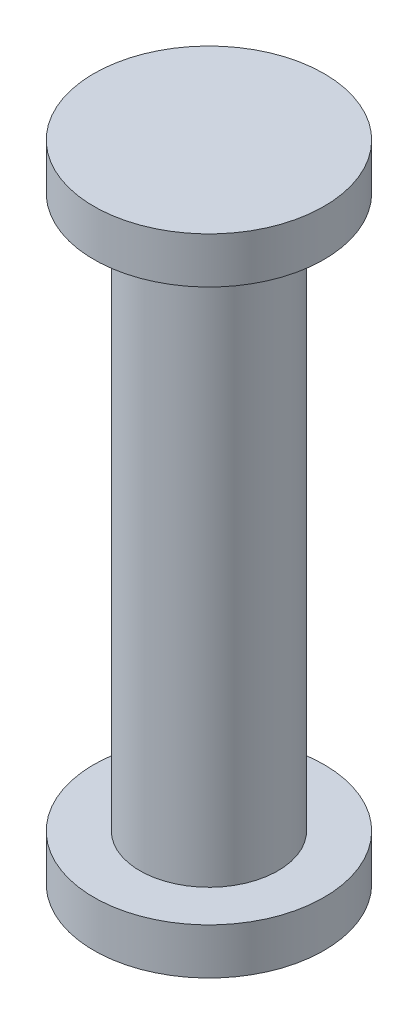
from build123d import *


with BuildPart() as part:
    # Sketch1 → Revolve1 (revolve)
    with BuildSketch(Plane.XY):
        Polygon((0, 0), (0, 14), (-2.5, 14), (-2.5, 13), (-1.5, 13), (-1.5, 1), (-2.5, 1), (-2.5, 0), align=None)
    revolve(axis=Axis((0, 0, 0), (0, 1, 0)))


solid = part.part
